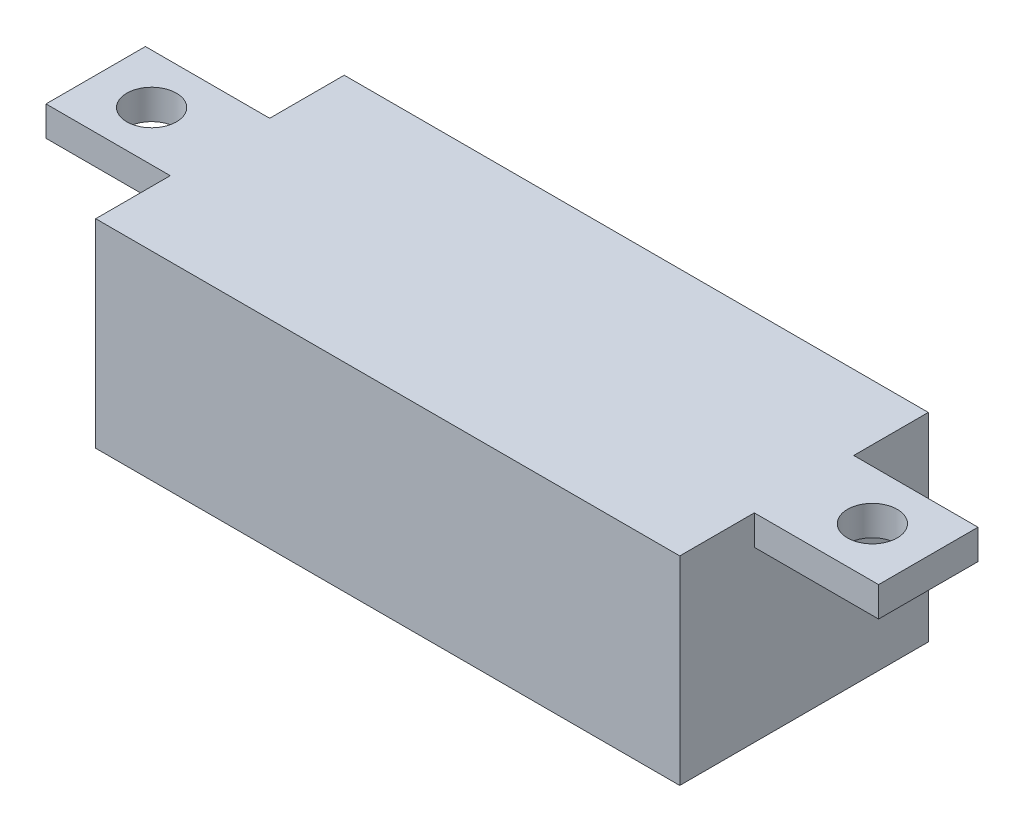
from build123d import *

# Parameters (mm, degrees)
SKETCH1_W           = 23.5
SKETCH1_H           = 10
BOSS_EXTRUDE1_DEPTH = 8
SKETCH2_W           = 10
SKETCH2_H           = 4
SKETCH2_R           = 1
BOSS_EXTRUDE2_DEPTH = 1.2


with BuildPart() as part:
    # Sketch1 → Boss-Extrude1 (new body)
    with BuildSketch(Plane(origin=(0, 0, 0), x_dir=(1, 0, 0), z_dir=(0, 1, 0))):
        Rectangle(SKETCH1_W, SKETCH1_H)
    extrude(amount=BOSS_EXTRUDE1_DEPTH)

    # Sketch2 → Boss-Extrude2 (add)
    with BuildSketch(Plane(origin=(0, 8, 0), x_dir=(1, 0, 0), z_dir=(0, 1, 0))):
        with Locations((11.75, 0)):
            Rectangle(SKETCH2_W, SKETCH2_H)
        with Locations((14.5, 0)):
            Circle(SKETCH2_R, mode=Mode.SUBTRACT)
        with Locations((-11.75, 0)):
            Rectangle(SKETCH2_W, SKETCH2_H)
        with Locations((-14.5, 0)):
            Circle(SKETCH2_R, mode=Mode.SUBTRACT)
    extrude(amount=-BOSS_EXTRUDE2_DEPTH)


solid = part.part
